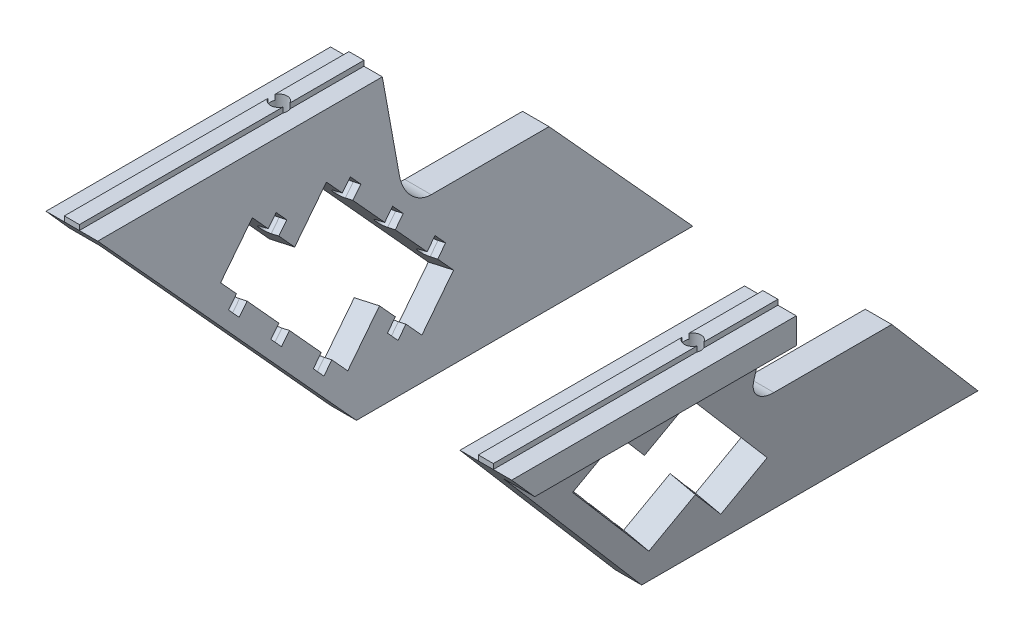
from build123d import *

# Parameters (mm, degrees)
MAIN_DEPTH               = 52.5
SKETCH3_R                = 1.6
MAKERBEAMFIXHOLES_DEPTH  = 47
SIDECUT_DEPTH            = 21
SIDECUT_DEPTH_BACK       = 1
CENTRALCUT_DEPTH         = 10
ROLLERSUPPORTHOLES_DEPTH = 2.5
LPATTERN1_COUNT          = 3
LPATTERN1_PITCH          = 10
CUT_EXTRUDE1_DEPTH       = 25
CUT_EXTRUDE2_DEPTH       = 25
CUT_EXTRUDE3_DEPTH       = 7.5
SKETCH10_R               = 4.25
CUT_EXTRUDE5_DEPTH       = 5
SKETCH11_W               = 27.777777778
SKETCH11_H               = 35
CUT_EXTRUDE6_DEPTH       = 46
CUT_EXTRUDE6_DEPTH_BACK  = 1
FILLET1_R                = 5


with BuildPart() as part:
    # Sketch1 → Main (new body, symmetric)
    with BuildSketch(Plane.XY):
        Polygon((20, 45), (20, 40), (14.010858032, 40), (5.121969143, 0), (0, 0), (10, 45), (13.55, 45), (13.55, 46), (16.45, 46), (16.45, 45), align=None)
    extrude(amount=MAIN_DEPTH, both=True)

    # Sketch3 → MakerBeamFixHoles (cut, through all)
    with BuildSketch(Plane(origin=(0, 46, 0), x_dir=(1, 0, 0), z_dir=(0, 1, 0))):
        with Locations((15, -12.5)):
            Circle(SKETCH3_R)
    extrude(amount=-MAKERBEAMFIXHOLES_DEPTH, mode=Mode.SUBTRACT)

    # Sketch2 → SideCut (cut, two sides)
    with BuildSketch(Plane(origin=(0, 40.615528128, 0), x_dir=(0, 0, 1), z_dir=(1, 0, 0))) as sidecut_sk:
        Polygon((-52.5, 40.615528128), (-12.5, -4.384471872), (-12.5, -5.384471872), (-52.5, -5.384471872), align=None)
        Polygon((52.5, -4.384471872), (52.5, 40.615528128), (12.5, 40.615528128), align=None)
    extrude(amount=SIDECUT_DEPTH, mode=Mode.SUBTRACT)
    extrude(sidecut_sk.sketch, amount=-SIDECUT_DEPTH_BACK, mode=Mode.SUBTRACT)

    # Sketch5 → CentralCut (cut)
    with BuildSketch(Plane(origin=(0, 0, 0), x_dir=(0, 0, 1), z_dir=(-0.97618706, 0.216930458, 0))):
        Polygon((24.631214246, 36.867825412), (18.077358881, 29.3148803), (10.524413769, 35.868735664), (-9.137152323, 13.209900328), (-1.584207211, 6.656044963), (4.969648153, 14.208990076), (12.522593265, 7.655134711), (32.184159358, 30.313970048), align=None)
    extrude(amount=-CENTRALCUT_DEPTH, mode=Mode.SUBTRACT)

    # Sketch4 → RollerSupportHoles (cut)
    with BuildSketch(Plane(origin=(-0.631416457, 4.658737233, 9.707435372), x_dir=(-0.989841813, 0.091892801, -0.108484557), z_dir=(-0.142173084, -0.63977888, 0.755294511))):
        with BuildLine():
            Line((-6.246856698, -27.389225103), (-6.660676315, -29.854737894))
            Line((-6.660676315, -29.854737894), (-8.13998399, -29.606446124))
            ThreePointArc((-8.13998399, -29.606446124), (-9.165830577, -28.166779919), (-7.726164372, -27.140933332))
            Line((-7.726164372, -27.140933332), (-6.246856698, -27.389225103))
        make_face()
    rollersupportholes = extrude(amount=ROLLERSUPPORTHOLES_DEPTH, mode=Mode.SUBTRACT)

    # LPattern1: RollerSupportHoles ×3
    with Locations(*[Vector(-0.163846384, -0.737308728, -0.655385536) * (i * LPATTERN1_PITCH) for i in range(1, LPATTERN1_COUNT)]):
        add(rollersupportholes, mode=Mode.SUBTRACT)

    # Sketch6 → Cut-Extrude1 (cut)
    with BuildSketch(Plane(origin=(-0.986849168, -4.440821256, 5.242636205), x_dir=(-0.989841813, 0.091892801, -0.108484557), z_dir=(0.142173084, 0.63977888, -0.755294511))):
        with BuildLine():
            Line((-5.005397845, 29.821864147), (-4.591578228, 27.356351355))
            Line((-4.591578228, 27.356351355), (-6.070885903, 27.108059585))
            ThreePointArc((-6.070885903, 27.108059585), (-7.510552107, 28.133906172), (-6.48470552, 29.573572376))
            Line((-6.48470552, 29.573572376), (-5.005397845, 29.821864147))
        make_face()
    extrude(amount=CUT_EXTRUDE1_DEPTH, mode=Mode.SUBTRACT)

    # Mirror5: RollerSupportHoles across plane
    add(rollersupportholes.mirror(Plane(origin=(0.079448965, 0.357520344, -0.422072629), x_dir=(0.163846384, 0.737308728, 0.655385536), z_dir=(0.142173084, 0.63977888, -0.755294511))), mode=Mode.SUBTRACT)

    # Sketch7 → Cut-Extrude2 (cut)
    with BuildSketch(Plane(origin=(-0.986849168, -4.440821256, 5.242636205), x_dir=(-0.989841813, 0.091892801, -0.108484557), z_dir=(0.142173084, 0.63977888, -0.755294511))):
        with BuildLine():
            Line((-4.415607433, 17.246008419), (-2.936299758, 17.49430019))
            Line((-2.936299758, 17.49430019), (-3.350119375, 19.959812981))
            Line((-3.350119375, 19.959812981), (-4.82942705, 19.711521211))
            ThreePointArc((-4.82942705, 19.711521211), (-5.855273637, 18.271855006), (-4.415607433, 17.246008419))
        make_face()
    extrude(amount=CUT_EXTRUDE2_DEPTH, mode=Mode.SUBTRACT)

    # Sketch8 → Cut-Extrude3 (cut, symmetric)
    with BuildSketch(Plane(origin=(1.50117981, 6.755309145, -7.975017741), x_dir=(-0.989841813, 0.091892801, -0.108484557), z_dir=(0.142173084, 0.63977888, -0.755294511))):
        with BuildLine():
            Line((-2.760328963, 7.383957254), (-1.281021288, 7.632249025))
            Line((-1.281021288, 7.632249025), (-1.694840906, 10.097761816))
            Line((-1.694840906, 10.097761816), (-3.17414858, 9.849470045))
            ThreePointArc((-3.17414858, 9.849470045), (-4.199995167, 8.409803841), (-2.760328963, 7.383957254))
        make_face()
    extrude(amount=CUT_EXTRUDE3_DEPTH, both=True, mode=Mode.SUBTRACT)

    # Sketch10 → Cut-Extrude5 (cut)
    with BuildSketch(Plane.XZ.offset(-40)):
        with Locations((15, 12.5)):
            Circle(SKETCH10_R)
    extrude(amount=CUT_EXTRUDE5_DEPTH, mode=Mode.SUBTRACT)

    # Sketch11 → Cut-Extrude6 (cut, two sides)
    with BuildSketch(Plane(origin=(-25, -227.744305716, 0), x_dir=(0, 0, 1), z_dir=(1, 0, 0))) as cut_extrude6_sk:
        with Locations((-16.388888889, -270.244305716)):
            Rectangle(SKETCH11_W, SKETCH11_H)
    extrude(amount=CUT_EXTRUDE6_DEPTH, mode=Mode.SUBTRACT)
    extrude(cut_extrude6_sk.sketch, amount=-CUT_EXTRUDE6_DEPTH_BACK, mode=Mode.SUBTRACT)

    # Fillet1
    fillet1_edges = [part.edges().sort_by_distance(p)[0] for p in [
        (8.116540127, 25, -2.5),
    ]]
    fillet(fillet1_edges, radius=FILLET1_R)


with BuildPart() as body_2:
    # Mirror7: mirrored copy
    add(part.part.mirror(Plane(origin=(-25, 0, 0), x_dir=(0, 0, 1), z_dir=(1, 0, 0))))


solid = Compound([part.part, body_2.part])
